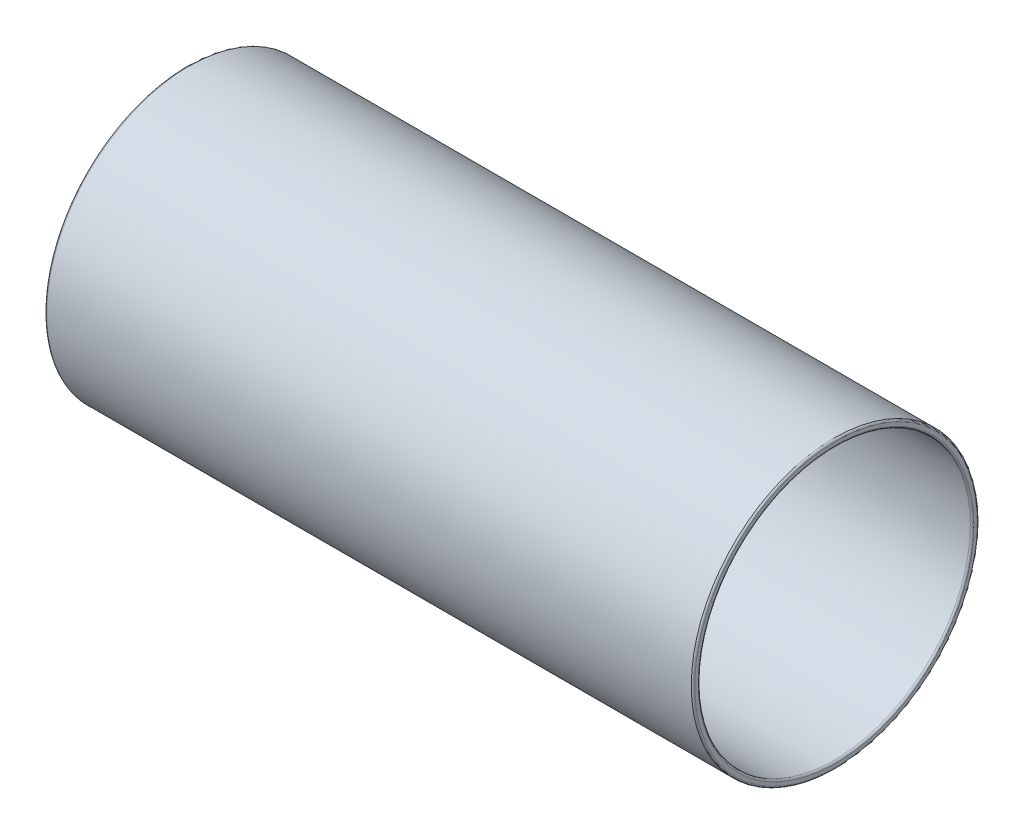
from build123d import *

# Parameters (mm, degrees)
SKETCH1_R           = 165.5
BOSS_EXTRUDE1_DEPTH = 750
SKETCH2_R           = 157.5
CUT_EXTRUDE1_DEPTH  = 750
FILLET1_R           = 2
FILLET2_R           = 2


with BuildPart() as part:
    # Sketch1 → Boss-Extrude1 (new body)
    with BuildSketch(Plane(origin=(0, 0, 0), x_dir=(0, 0, -1), z_dir=(1, 0, 0))):
        Circle(SKETCH1_R)
    extrude(amount=-BOSS_EXTRUDE1_DEPTH)

    # Sketch2 → Cut-Extrude1 (cut)
    with BuildSketch(Plane(origin=(0, 0, 0), x_dir=(0, 0, -1), z_dir=(1, 0, 0))):
        Circle(SKETCH2_R)
    extrude(amount=-CUT_EXTRUDE1_DEPTH, mode=Mode.SUBTRACT)

    # Fillet1
    fillet1_edges = [part.edges().sort_by_distance(p)[0] for p in [
        (0, 0, 165.5),
        (0, 0, 157.5),
    ]]
    fillet(fillet1_edges, radius=FILLET1_R)

    # Fillet2
    fillet2_edges = [part.edges().sort_by_distance(p)[0] for p in [
        (-750, 0, 165.5),
        (-750, 0, 157.5),
    ]]
    fillet(fillet2_edges, radius=FILLET2_R)


solid = part.part
